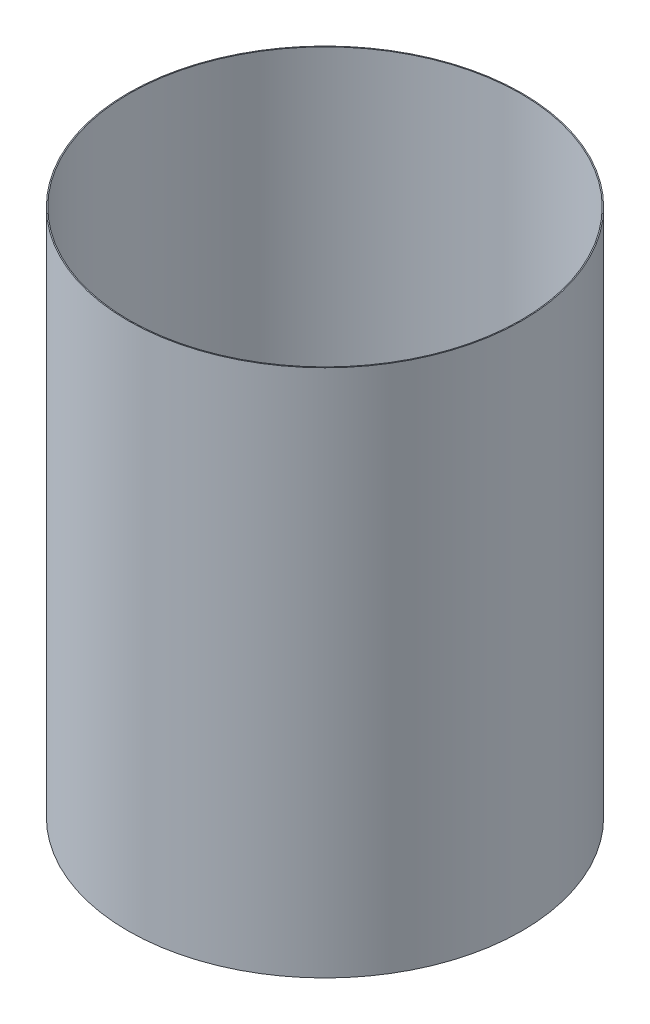
from build123d import *

# Parameters (mm, degrees)
SKETCH1_W = 0.254
SKETCH1_H = 133.35


with BuildPart() as part:
    # Sketch1 → Revolve-Thin1 (revolve)
    with BuildSketch(Plane.XY):
        with Locations((-49.5935, -86.580914232)):
            Rectangle(SKETCH1_W, SKETCH1_H)
    revolve(axis=Axis((0, 55, 0), (0, -1, 0)))


solid = part.part
